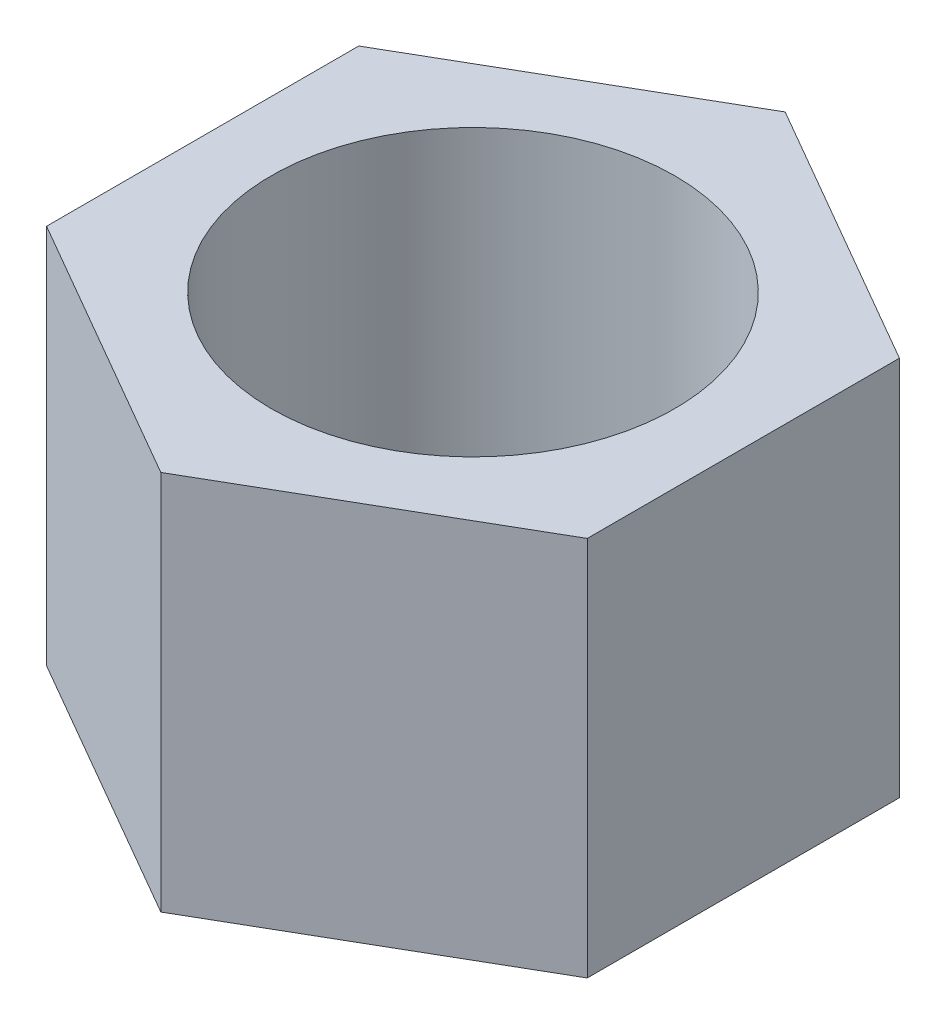
from build123d import *

# Parameters (mm, degrees)
SKETCH2_R           = 2.65
BOSS_EXTRUDE1_DEPTH = 5


with BuildPart() as part:
    # Sketch2 → Boss-Extrude1 (new body)
    with BuildSketch(Plane(origin=(0, 0, 0), x_dir=(1, 0, 0), z_dir=(0, 1, 0))):
        Polygon((-3.550704156, 2.05), (0, 4.1), (3.550704156, 2.05), (3.550704156, -2.05), (0, -4.1), (-3.550704156, -2.05), align=None)
        Circle(SKETCH2_R, mode=Mode.SUBTRACT)
    extrude(amount=BOSS_EXTRUDE1_DEPTH)


solid = part.part
